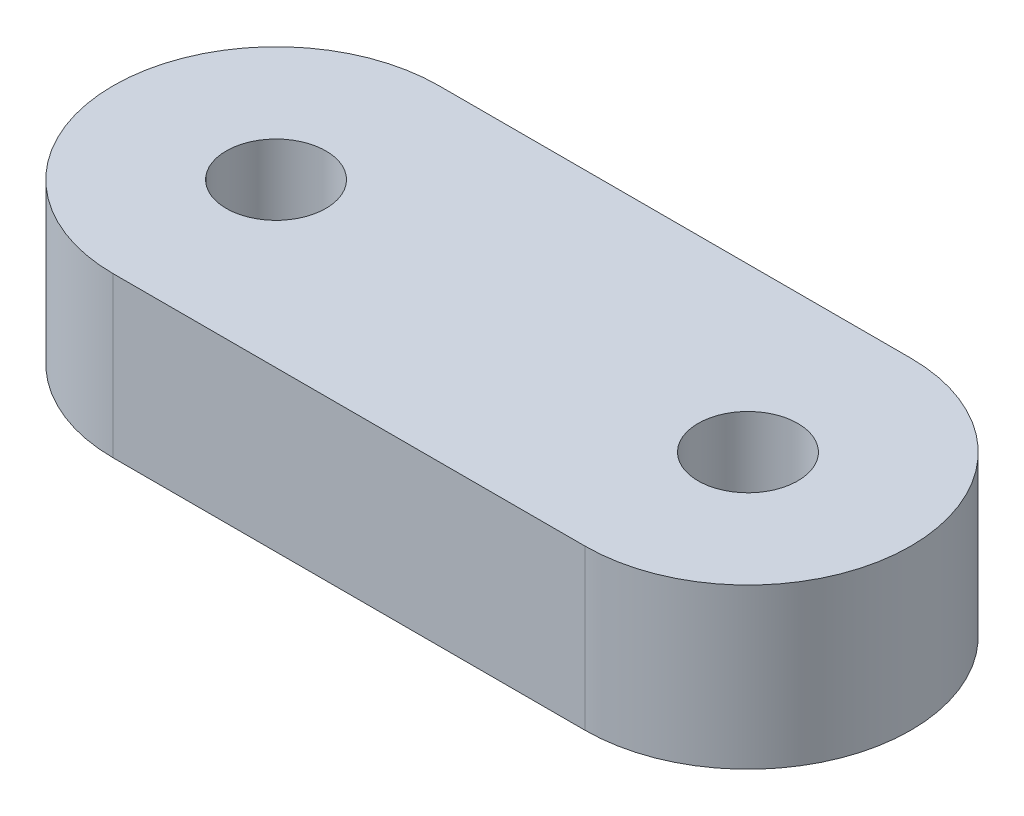
from build123d import *

# Parameters (mm, degrees)
SKETCH1_R           = 1.5
BOSS_EXTRUDE1_DEPTH = 4.8


with BuildPart() as part:
    # Sketch1 → Boss-Extrude1 (new body)
    with BuildSketch(Plane(origin=(0, 0, 0), x_dir=(1, 0, 0), z_dir=(0, 1, 0))):
        with BuildLine():
            Line((-7.099999442, 4.9), (7.099999442, 4.9))
            ThreePointArc((7.099999442, 4.9), (12, 0), (7.099999442, -4.9))
            Line((7.099999442, -4.9), (-7.099999442, -4.9))
            ThreePointArc((-7.099999442, -4.9), (-12, 0), (-7.099999442, 4.9))
        make_face()
        with Locations((-7.1, 0)):
            Circle(SKETCH1_R, mode=Mode.SUBTRACT)
        with Locations((7.1, 0)):
            Circle(SKETCH1_R, mode=Mode.SUBTRACT)
    extrude(amount=BOSS_EXTRUDE1_DEPTH)


solid = part.part
